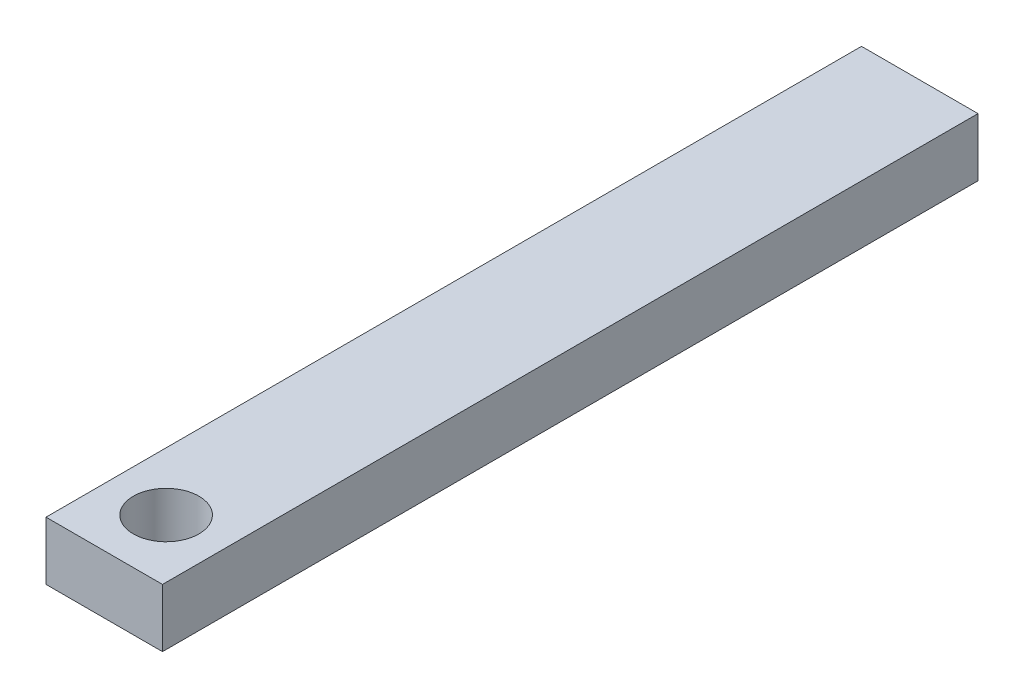
from build123d import *

# Parameters (mm, degrees)
SKETCH1_W           = 50.8
SKETCH1_H           = 25.4
BOSS_EXTRUDE1_DEPTH = 355.6
SKETCH2_R           = 14.2875
CUT_EXTRUDE1_DEPTH  = 26.4


with BuildPart() as part:
    # Sketch1 → Boss-Extrude1 (new body)
    with BuildSketch(Plane.XY):
        with Locations((25.4, 12.7)):
            Rectangle(SKETCH1_W, SKETCH1_H)
    extrude(amount=BOSS_EXTRUDE1_DEPTH)

    # Sketch2 → Cut-Extrude1 (cut, through all)
    with BuildSketch(Plane(origin=(0, 25.4, 0), x_dir=(1, 0, 0), z_dir=(0, 1, 0))):
        with Locations((25.4, -328.6125)):
            Circle(SKETCH2_R)
    extrude(amount=-CUT_EXTRUDE1_DEPTH, mode=Mode.SUBTRACT)


solid = part.part
